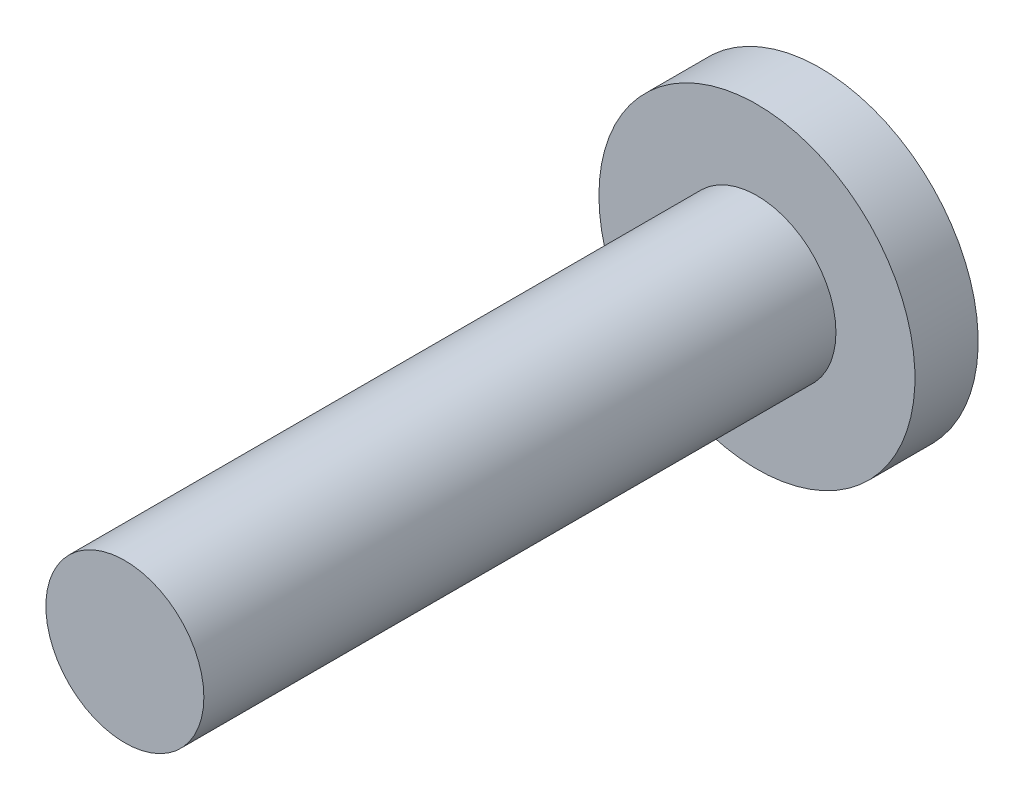
from build123d import *

# Parameters (mm, degrees)
SKETCH1_R           = 3.175
BOSS_EXTRUDE1_DEPTH = 25.4
SKETCH2_R           = 6.35
BOSS_EXTRUDE2_DEPTH = 2.54


with BuildPart() as part:
    # Sketch1 → Boss-Extrude1 (new body)
    with BuildSketch(Plane.XY):
        Circle(SKETCH1_R)
    extrude(amount=BOSS_EXTRUDE1_DEPTH)

    # Sketch2 → Boss-Extrude2 (add)
    with BuildSketch(Plane(origin=(0, 0, 0), x_dir=(-1, 0, 0), z_dir=(0, 0, -1))):
        Circle(SKETCH2_R)
    extrude(amount=BOSS_EXTRUDE2_DEPTH)


solid = part.part
